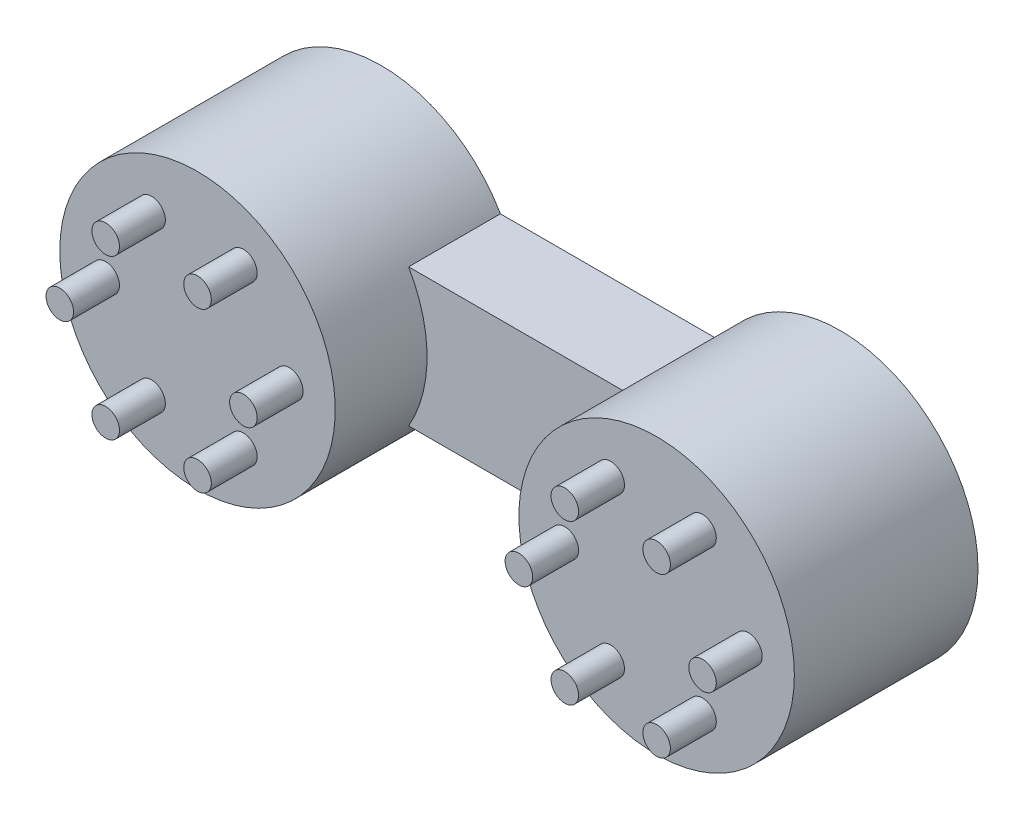
from build123d import *

# Parameters (mm, degrees)
SKETCH1_R             = 15
BOSS_EXTRUDE1_DEPTH   = 20
BOSS_EXTRUDE1_2_DEPTH = 20
SKETCH2_R             = 1.5
BOSS_EXTRUDE2_DEPTH   = 5
SKETCH3_W             = 50
SKETCH3_H             = 15
BOSS_EXTRUDE3_DEPTH   = 10


with BuildPart() as part:
    # Sketch1 → Boss-Extrude1 (new body)
    with BuildSketch(Plane.XY):
        with Locations((25, 0)):
            Circle(SKETCH1_R)
    extrude(amount=BOSS_EXTRUDE1_DEPTH)



with BuildPart() as body_2:
    # Sketch1 → Boss-Extrude1 2 (new body)
    with BuildSketch(Plane.XY):
        with Locations((-25, 0)):
            Circle(SKETCH1_R)
    extrude(amount=BOSS_EXTRUDE1_2_DEPTH)


with BuildPart() as part_1:
    add(part.part)

    add(body_2.part)  # Boss-Extrude2 merges body 2
    # Sketch2 → Boss-Extrude2 (add)
    with BuildSketch(Plane.XY.offset(20)):
        with Locations((35, 0)):
            Circle(SKETCH2_R)
        with Locations((30, -8.660254038)):
            Circle(SKETCH2_R)
        with Locations((20, -8.660254038)):
            Circle(SKETCH2_R)
        with Locations((15, 0)):
            Circle(SKETCH2_R)
        with Locations((20, 8.660254038)):
            Circle(SKETCH2_R)
        with Locations((30, 8.660254038)):
            Circle(SKETCH2_R)
        with Locations((-15, 0)):
            Circle(SKETCH2_R)
        with Locations((-20, -8.660254038)):
            Circle(SKETCH2_R)
        with Locations((-30, -8.660254038)):
            Circle(SKETCH2_R)
        with Locations((-35, 0)):
            Circle(SKETCH2_R)
        with Locations((-30, 8.660254038)):
            Circle(SKETCH2_R)
        with Locations((-20, 8.660254038)):
            Circle(SKETCH2_R)
    extrude(amount=BOSS_EXTRUDE2_DEPTH)

    # Sketch3 → Boss-Extrude3 (add)
    with BuildSketch(Plane.XY):
        Rectangle(SKETCH3_W, SKETCH3_H)
    extrude(amount=BOSS_EXTRUDE3_DEPTH)


solid = part_1.part
